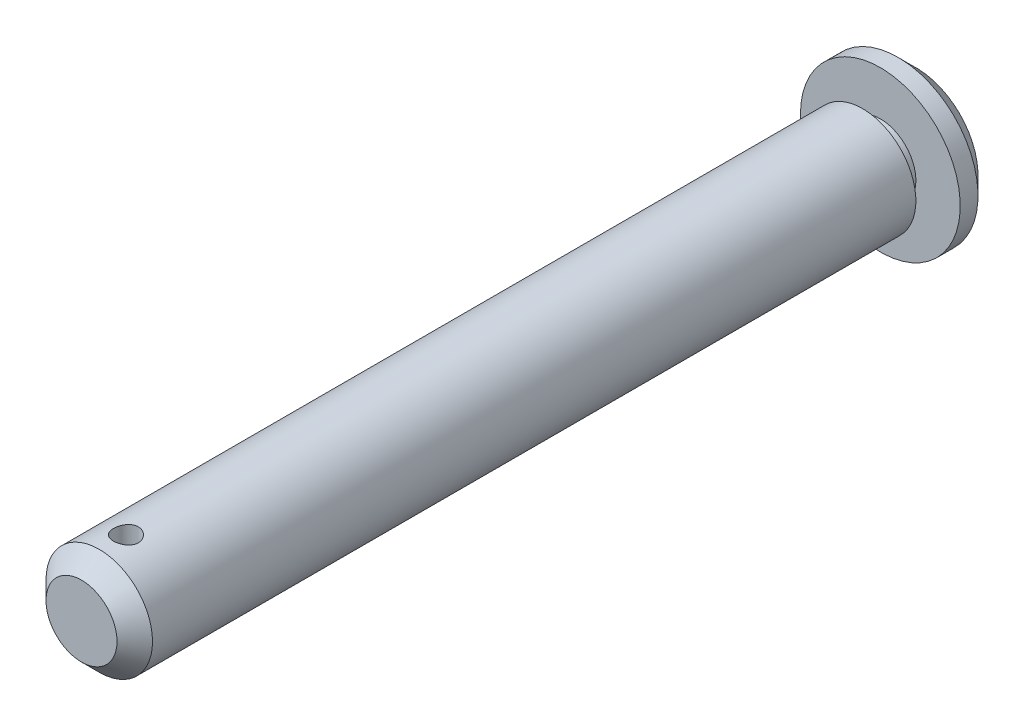
from build123d import *

# Parameters (mm, degrees)
SKETCH_2_R               = 0.7
CUT_EXTRUDE_1_DEPTH      = 5.5
CUT_EXTRUDE_1_DEPTH_BACK = 5.5
CHAMFER_1_SIZE           = 1


with BuildPart() as part:
    # 草图1 → 旋转1 (revolve)
    with BuildSketch(Plane(origin=(0, 0, 0), x_dir=(1, 0, 0), z_dir=(0, 1, 0))):
        Polygon((0, 0), (-3, 0), (-3, 44), (-2, 44), (-2, 45), (-4.5, 45), (-4.5, 47), (0, 47), align=None)
    revolve(axis=Axis((0, 0, -47), (0, 0, 1)))

    # 草图2 → 切除-拉伸1 (cut, two sides)
    with BuildSketch(Plane(origin=(0, 0, 0), x_dir=(1, 0, 0), z_dir=(0, 1, 0))) as cut_extrude_1_sk:
        with Locations((0, 2.5)):
            Circle(SKETCH_2_R)
    extrude(amount=CUT_EXTRUDE_1_DEPTH, mode=Mode.SUBTRACT)
    extrude(cut_extrude_1_sk.sketch, amount=-CUT_EXTRUDE_1_DEPTH_BACK, mode=Mode.SUBTRACT)

    # 倒角1
    chamfer_1_edges = [part.edges().sort_by_distance(p)[0] for p in [
        (4.5, 0, -47),
        (3, 0, 0),
    ]]
    chamfer(chamfer_1_edges, length=CHAMFER_1_SIZE)


solid = part.part
